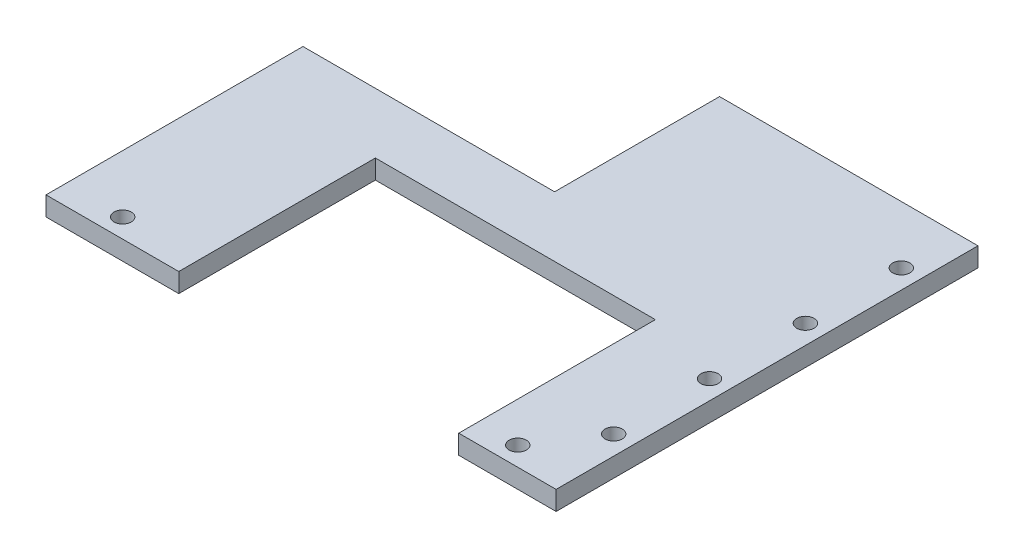
from build123d import *

# Parameters (mm, degrees)
SKETCH1_R           = 2.25
BOSS_EXTRUDE1_DEPTH = 5
CUT_EXTRUDE1_DEPTH  = 5


with BuildPart() as part:
    # Sketch1 → Boss-Extrude1 (new body)
    with BuildSketch(Plane(origin=(0, 0, 0), x_dir=(1, 0, 0), z_dir=(0, 1, 0))):
        Polygon((0, 55.733260811), (0, 12.733260811), (-65.613421019, 12.733260811), (-65.613421019, -54.266739189), (67.386578981, -54.266739189), (67.386578981, 55.733260811), align=None)
        with Locations((62.386578981, 40.733260811)):
            Circle(SKETCH1_R, mode=Mode.SUBTRACT)
        with Locations((62.386578981, 15.733260811)):
            Circle(SKETCH1_R, mode=Mode.SUBTRACT)
        with Locations((62.386578981, -9.266739189)):
            Circle(SKETCH1_R, mode=Mode.SUBTRACT)
        with Locations((62.386578981, -34.266739189)):
            Circle(SKETCH1_R, mode=Mode.SUBTRACT)
        with Locations((0.886578981, -49.266739189)):
            Circle(SKETCH1_R, mode=Mode.SUBTRACT)
        with Locations((-50.613421019, -49.266739189)):
            Circle(SKETCH1_R, mode=Mode.SUBTRACT)
        with Locations((52.386578981, -49.266739189)):
            Circle(SKETCH1_R, mode=Mode.SUBTRACT)
    extrude(amount=BOSS_EXTRUDE1_DEPTH)

    # Sketch2 → Cut-Extrude1 (cut)
    with BuildSketch(Plane(origin=(0, 5, 0), x_dir=(1, 0, 0), z_dir=(0, 1, 0))):
        Polygon((-8, -3), (42, -3), (42, -54.266739189), (-8, -54.266739189), (-31, -54.266739189), (-31, -3), align=None)
    extrude(amount=-CUT_EXTRUDE1_DEPTH, mode=Mode.SUBTRACT)


solid = part.part
